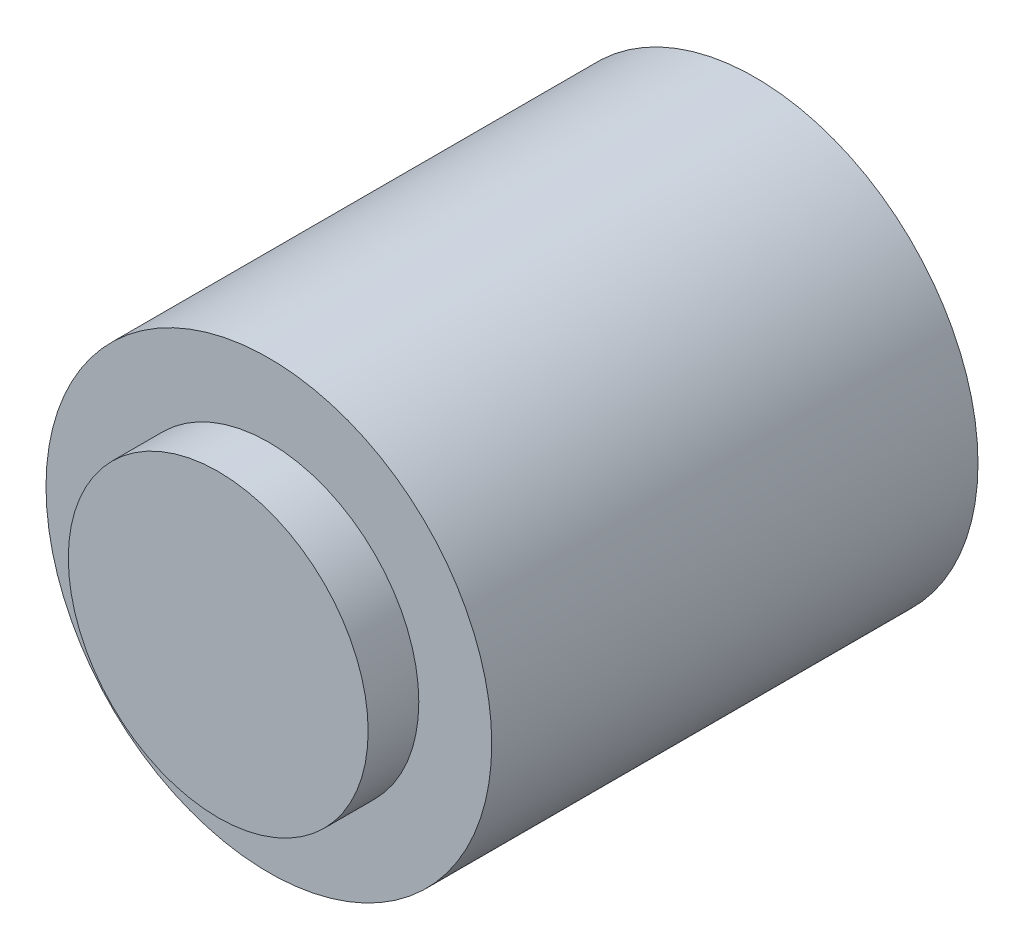
from build123d import *

# Parameters (mm, degrees)
SKETCH1_R      = 11
EXTRUDE1_DEPTH = 24
SKETCH2_R      = 7.4
EXTRUDE3_DEPTH = 2.5
SKETCH3_R      = 3.65
EXTRUDE4_DEPTH = 1.3
SKETCH4_R      = 1.5
EXTRUDE5_DEPTH = 5


with BuildPart() as part:
    # Sketch1 → Extrude1 (new body)
    with BuildSketch(Plane.XY):
        Circle(SKETCH1_R)
    extrude(amount=EXTRUDE1_DEPTH)

    # Sketch2 → Extrude3 (add)
    with BuildSketch(Plane.XY.offset(24)):
        Circle(SKETCH2_R)
    extrude(amount=EXTRUDE3_DEPTH)

    # Sketch3 → Extrude4 (add)
    with BuildSketch(Plane(origin=(0, 0, 0), x_dir=(-1, 0, 0), z_dir=(0, 0, -1))):
        Circle(SKETCH3_R)
    extrude(amount=EXTRUDE4_DEPTH)

    # Sketch4 → Extrude5 (add)
    with BuildSketch(Plane(origin=(0, 0, -1.3), x_dir=(-1, 0, 0), z_dir=(0, 0, -1))):
        Circle(SKETCH4_R)
    extrude(amount=EXTRUDE5_DEPTH)


solid = part.part
